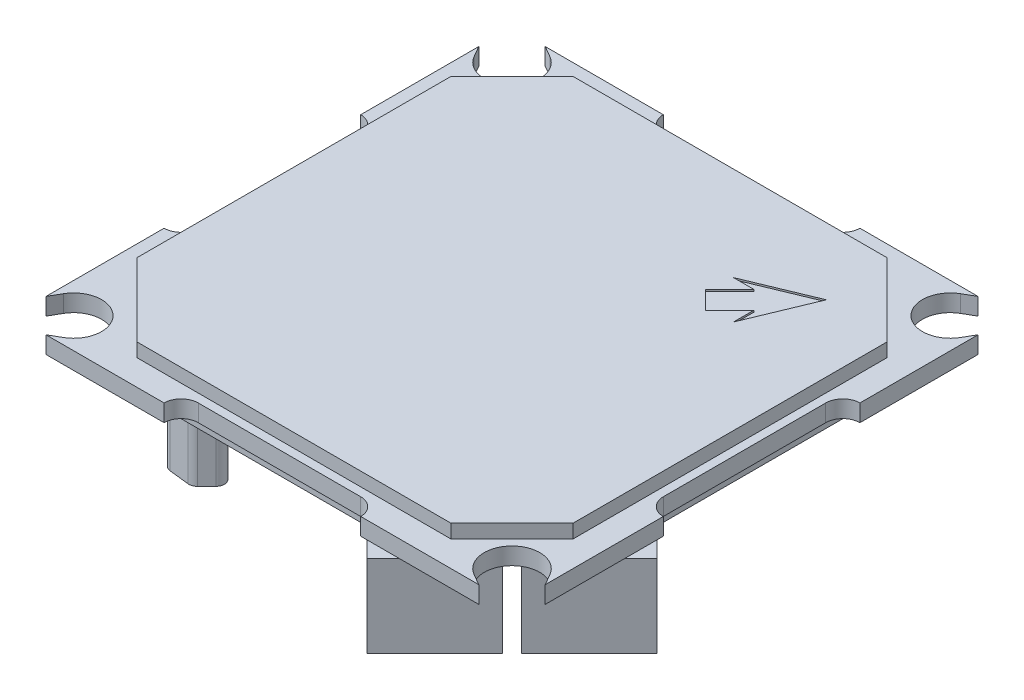
from build123d import *

# Parameters (mm, degrees)
SKETCH1_W            = 29.2
SKETCH1_H            = 29.2
BOSS_EXTRUDE1_DEPTH  = 0.5
CUT_EXTRUDE1_START   = -2
CUT_EXTRUDE1_DEPTH   = 3
BOSS_EXTRUDE3_DEPTH  = 0.8
CUT_EXTRUDE4_START   = -1.5
CUT_EXTRUDE4_DEPTH   = 3.8
SKETCH10_OUTSIDE_W   = 53.166
SKETCH10_OUTSIDE_H   = 53.166
SKETCH10_OUTSIDE_W_2 = 26.2
SKETCH10_OUTSIDE_H_2 = 26.2
CUT_EXTRUDE9_DEPTH   = 0.8
CIRPATTERN1_COUNT    = 4
BOSS_EXTRUDE2_DEPTH  = 4.8
BOSS_EXTRUDE4_DEPTH  = 0.8
CUT_EXTRUDE10_DEPTH  = 0.1
BOSS_EXTRUDE5_DEPTH  = 5
FILLET1_R            = 0.5
SKETCH14_R           = 0.675
BOSS_EXTRUDE7_DEPTH  = 5


with BuildPart() as part:
    # Sketch1 → Boss-Extrude1 (new body, symmetric)
    with BuildSketch(Plane(origin=(0, 0, 0), x_dir=(1, 0, 0), z_dir=(0, 1, 0))):
        Rectangle(SKETCH1_W, SKETCH1_H)
    extrude(amount=BOSS_EXTRUDE1_DEPTH, both=True)

    # Sketch2 → Cut-Extrude1 (cut)
    with BuildSketch(Plane(origin=(0, 0.5, 0), x_dir=(1, 0, 0), z_dir=(0, 1, 0)).offset(CUT_EXTRUDE1_START)):
        with BuildLine():
            Line((-13.6, 4.75), (-13.6, -4.75))
            ThreePointArc((-13.6, -4.75), (-14.6, -5.75), (-15.6, -4.75))
            Line((-15.6, -4.75), (-15.6, 4.75))
            ThreePointArc((-15.6, 4.75), (-14.6, 5.75), (-13.6, 4.75))
        make_face()
    cut_extrude1 = extrude(amount=CUT_EXTRUDE1_DEPTH, mode=Mode.SUBTRACT)

    # Sketch6 → Boss-Extrude3 (add)
    with BuildSketch(Plane(origin=(0, 0.5, 0), x_dir=(1, 0, 0), z_dir=(0, 1, 0))):
        Polygon((19.940411229, 1.979898987), (-1.979898987, -19.940411229), (-19.940411229, -1.979898987), (1.979898987, 19.940411229), align=None)
    boss_extrude3 = extrude(amount=BOSS_EXTRUDE3_DEPTH)

    # Sketch4 → Cut-Extrude4 (cut)
    with BuildSketch(Plane(origin=(0, 0, 0), x_dir=(1, 0, 0), z_dir=(0, 1, 0)).offset(CUT_EXTRUDE4_START)):
        with BuildLine():
            Line((-14.22360169, 12.003810409), (-14.6, 12.655751406))
            Line((-14.6, 12.655751406), (-14.6, 14.6))
            Line((-14.6, 14.6), (-12.655751406, 14.6))
            Line((-12.655751406, 14.6), (-12.003810409, 14.22360169))
            ThreePointArc((-12.003810409, 14.22360169), (-11.66726189, 11.66726189), (-14.22360169, 12.003810409))
        make_face()
    cut_extrude4 = extrude(amount=CUT_EXTRUDE4_DEPTH, mode=Mode.SUBTRACT)

    # Sketch10 outside → Cut-Extrude9 (cut)
    with BuildSketch(Plane(origin=(0, 1.3, 0), x_dir=(1, 0, 0), z_dir=(0, 1, 0))):
        Rectangle(SKETCH10_OUTSIDE_W, SKETCH10_OUTSIDE_H)
        Rectangle(SKETCH10_OUTSIDE_W_2, SKETCH10_OUTSIDE_H_2, mode=Mode.SUBTRACT)
    cut_extrude9 = extrude(amount=-CUT_EXTRUDE9_DEPTH, mode=Mode.SUBTRACT)

    # CirPattern1: Cut-Extrude1, Cut-Extrude4 ×4 about axis
    cirpattern1_axis = Axis((0, 0, 0), (0, 1, 0))
    for i in range(1, CIRPATTERN1_COUNT):
        add(cut_extrude1.rotate(cirpattern1_axis, i * 360 / CIRPATTERN1_COUNT), mode=Mode.SUBTRACT)
        add(cut_extrude4.rotate(cirpattern1_axis, i * 360 / CIRPATTERN1_COUNT), mode=Mode.SUBTRACT)

    # Mirror3: Boss-Extrude3, Cut-Extrude9 across plane
    add(boss_extrude3.mirror(Plane.ZX))
    add(cut_extrude9.mirror(Plane.ZX), mode=Mode.SUBTRACT)

    # Sketch5 → Boss-Extrude2 (add)
    with BuildSketch(Plane.XZ.offset(0.5)):
        Polygon((4.772970773, 13.258252147), (8.732768748, 9.298454173), (11.030865787, 11.596551211), (7.071067812, 15.556349186), align=None)
        Polygon((9.298454173, 8.732768748), (13.258252147, 4.772970773), (15.556349186, 7.071067812), (11.596551211, 11.030865787), align=None)
    boss_extrude2 = extrude(amount=BOSS_EXTRUDE2_DEPTH)

    # Mirror1: Boss-Extrude2 across plane
    add(boss_extrude2.mirror(Plane(origin=(0, 0, 0), x_dir=(-0.707106781, 0, 0.707106781), z_dir=(0.707106781, 0, 0.707106781))))

    # Sketch11 → Boss-Extrude4 (add)
    with BuildSketch(Plane(origin=(0, 0.5, 0), x_dir=(1, 0, 0), z_dir=(0, 1, 0))):
        Polygon((-4.860512242, 13.1), (-9.527416998, 13.1), (-13.1, 9.527416998), (-13.1, 4.860512242), align=None)
    boss_extrude4 = extrude(amount=BOSS_EXTRUDE4_DEPTH)

    # Mirror4: Boss-Extrude4 across plane
    add(boss_extrude4.mirror(Plane(origin=(0, 0, 0), x_dir=(-0.707106781, 0, 0.707106781), z_dir=(0.707106781, 0, 0.707106781))))

    # Sketch12 → Cut-Extrude10 (cut)
    with BuildSketch(Plane(origin=(0, 1.3, 0), x_dir=(1, 0, 0), z_dir=(0, 1, 0))):
        Polygon((9.192388155, 9.192388155), (5.351397898, 7.601397898), (6.540737726, 7.601397898), (5.126524164, 6.187184335), (6.187184335, 5.126524164), (7.601397898, 6.540737726), (7.601397898, 5.351397898), align=None)
    extrude(amount=-CUT_EXTRUDE10_DEPTH, mode=Mode.SUBTRACT)

    # Sketch13 → Boss-Extrude5 (add)
    with BuildSketch(Plane.XZ.offset(0.5)):
        Polygon((-5.656854249, 10.960155108), (-10.960155108, 5.656854249), (-12.02081528, 6.717514421), (-11.844038585, 8.308504679), (-8.308504679, 11.844038585), (-6.717514421, 12.02081528), align=None)
    extrude(amount=BOSS_EXTRUDE5_DEPTH)

    # Fillet1
    fillet1_edges = [part.edges().sort_by_distance(p)[0] for p in [
        (-5.656854249, -3.4, 10.960155108),
        (-6.717514421, -3.4, 12.02081528),
        (-8.308504679, -3.4, 11.844038585),
        (-11.844038585, -3.4, 8.308504679),
        (-12.02081528, -3.4, 6.717514421),
        (-10.960155108, -3.4, 5.656854249),
    ]]
    fillet(fillet1_edges, radius=FILLET1_R)

    # Sketch14 → Boss-Extrude7 (add)
    with BuildSketch(Plane.XZ.offset(0.5)):
        with Locations((-12.6, 2.6)):
            Circle(SKETCH14_R)
        with Locations((-12.6, 4.6)):
            Circle(SKETCH14_R)
    extrude(amount=BOSS_EXTRUDE7_DEPTH)


solid = part.part
